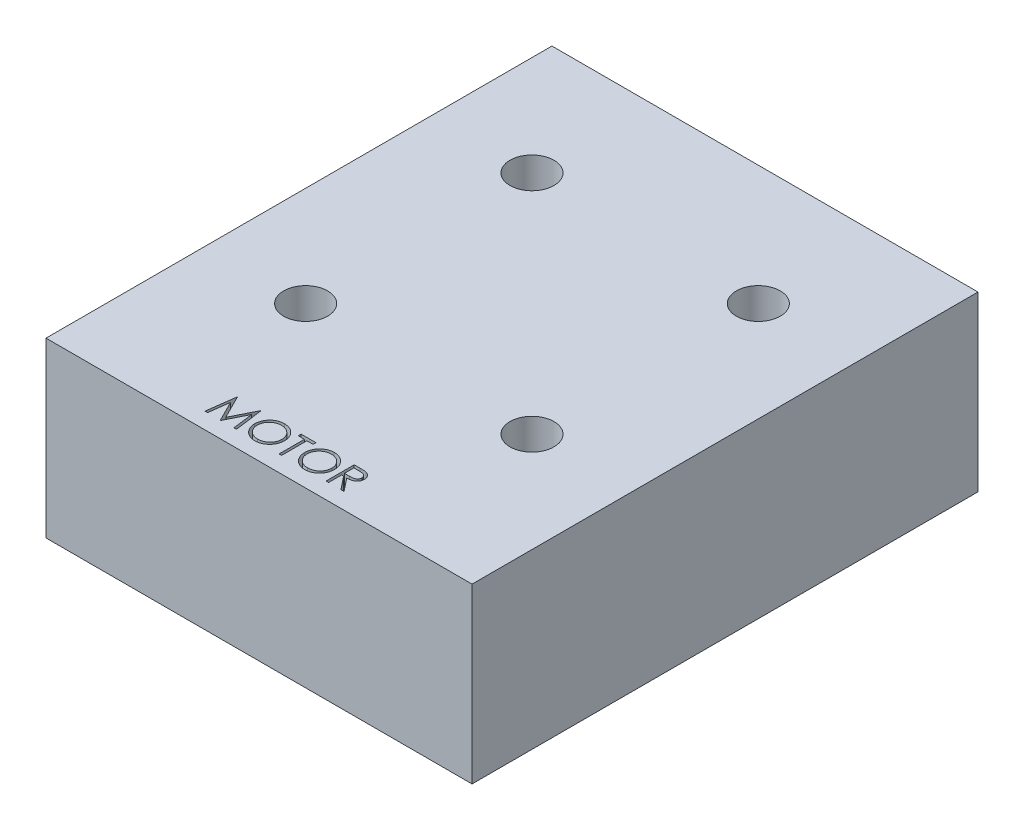
from build123d import *

# Parameters (mm, degrees)
SKETCH1_W                 = 16
SKETCH1_H                 = 13
BOSS_EXTRUDE1_DEPTH       = 19
M4X0_7_TAPPED_HOLE1_D     = 3.3
M4X0_7_TAPPED_HOLE1_DEPTH = 8
CUT_EXTRUDE1_DEPTH        = 1


with BuildPart() as part:
    # Sketch1 → Boss-Extrude1 (new, symmetric)
    with BuildSketch(Plane.XY):
        with Locations((-8, 6.5)):
            Rectangle(SKETCH1_W, SKETCH1_H)
    extrude(amount=BOSS_EXTRUDE1_DEPTH, both=True)

    # M4x0.7 Tapped Hole1
    with Locations(Plane(origin=(0, 13, 0), x_dir=(1, 0, 0), z_dir=(0, 1, 0))):
        with Locations((-8.5, 10), (-8.5, -7)):
            Hole(M4X0_7_TAPPED_HOLE1_D / 2, depth=M4X0_7_TAPPED_HOLE1_DEPTH)

    # Mirror1: part across plane


with BuildPart() as part_1:
    add(part.part)
    add(part.part.mirror(Plane(origin=(0, 0, 19), x_dir=(0, 0, 1), z_dir=(-1, 0, 0))))

    # Sketch9 → Cut-Extrude1 (cut)
    with BuildSketch(Plane(origin=(0, 13, 0), x_dir=(1, 0, 0), z_dir=(0, 1, 0))):
        Polygon((-5.278780125, -17.779725529), (-4.99935638, -15.663058862), (-4.972219628, -15.663058862), (-4.098331407, -17.399810999), (-3.226563244, -15.663058862), (-3.19900248, -15.663058862), (-2.917882689, -17.779725529), (-3.108687977, -17.779725529), (-3.311365595, -16.256675315), (-4.075434772, -17.779725529), (-4.118259959, -17.779725529), (-4.885297219, -16.253283221), (-5.087550825, -17.779725529), align=None)
        with BuildLine():
            add(Edge.make_bspline(
                [(-1.493203202, -15.608785358), (-1.454009728, -15.609778062), (-1.377030512, -15.611727815), (-1.263894741, -15.626652796), (-1.155887231, -15.652473342), (-1.052128147, -15.686861907), (-0.953858585, -15.73273575), (-0.860338874, -15.788183435), (-0.771791526, -15.853785865), (-0.689410024, -15.929035921), (-0.614022249, -16.010910676), (-0.547603737, -16.098285413), (-0.491940064, -16.190631831), (-0.44622866, -16.287672429), (-0.41036712, -16.389187743), (-0.385620841, -16.495718973), (-0.369813483, -16.606575876), (-0.367965466, -16.682187361), (-0.367027988, -16.720544172)],
                knots=[0, 0, 0, 0, 1.065120563, 2.091984664, 3.0946048, 4.079830382, 5.057816894, 6.036188127, 7.030412546, 8.04752943, 9.064399622, 10.05169764, 11.02544977, 11.989514704, 12.962713494, 13.945757189, 14.957906945, 16, 16, 16, 16], degree=3))
            add(Edge.make_bspline(
                [(-0.367027988, -16.720544172), (-0.367965328, -16.758618437), (-0.369812934, -16.833667225), (-0.385638814, -16.943820641), (-0.410458847, -17.049708824), (-0.445895637, -17.151155004), (-0.49138914, -17.248266198), (-0.547423458, -17.340786879), (-0.613427905, -17.428747381), (-0.688543476, -17.511184088), (-0.770428869, -17.586777796), (-0.858258601, -17.652647783), (-0.950057419, -17.709328563), (-1.047006623, -17.75455488), (-1.147820455, -17.790702661), (-1.253401193, -17.815348299), (-1.363254109, -17.831245701), (-1.438166573, -17.833071185), (-1.476242732, -17.833999033)],
                knots=[0, 0, 0, 0, 1.043624062, 2.057103931, 3.04512605, 4.022047818, 4.998200453, 5.980619268, 6.982898556, 8.009068085, 9.034988726, 10.034168286, 11.015286542, 11.987931943, 12.962482838, 13.94673481, 14.956375938, 16, 16, 16, 16], degree=3))
            add(Edge.make_bspline(
                [(-1.476242732, -17.833999033), (-1.514599344, -17.833062023), (-1.590210436, -17.831214926), (-1.701206643, -17.81538141), (-1.807812707, -17.790621669), (-1.909723767, -17.755237391), (-2.006996653, -17.709506971), (-2.099821608, -17.653745275), (-2.187826045, -17.587580004), (-2.270280339, -17.512488789), (-2.345723902, -17.430742184), (-2.411497429, -17.343151944), (-2.467271664, -17.251436501), (-2.512848537, -17.155341332), (-2.548931329, -17.055330983), (-2.573548052, -16.950738333), (-2.589475033, -16.842159679), (-2.591310392, -16.768231831), (-2.592241663, -16.730720454)],
                knots=[0, 0, 0, 0, 1.053102029, 2.075944431, 3.073151272, 4.055350789, 5.033113405, 6.020478099, 7.024410459, 8.052272461, 9.079885166, 10.07527673, 11.055994387, 12.023226415, 12.992069828, 13.970394897, 14.97016774, 16, 16, 16, 16], degree=3))
            add(Edge.make_bspline(
                [(-2.592241663, -16.730720454), (-2.591918336, -16.705542602), (-2.591275761, -16.655504527), (-2.583539832, -16.581199488), (-2.572314422, -16.508089423), (-2.556226599, -16.436382231), (-2.535185924, -16.366253445), (-2.510359222, -16.297219412), (-2.480036554, -16.229979732), (-2.445758257, -16.164215871), (-2.407499926, -16.100952994), (-2.365241734, -16.041154389), (-2.320467964, -15.984318263), (-2.271383435, -15.931917456), (-2.219605871, -15.882427578), (-2.164295328, -15.836609173), (-2.105789304, -15.794049083), (-2.043836055, -15.755694877), (-1.979962146, -15.721006258), (-1.914117618, -15.691238757), (-1.84719674, -15.665689949), (-1.778886071, -15.644982402), (-1.709367014, -15.628634456), (-1.63848784, -15.61750239), (-1.566305015, -15.609746731), (-1.517675313, -15.609107194), (-1.493203202, -15.608785358)],
                knots=[0, 0, 0, 0, 1.037015668, 2.060948919, 3.074880161, 4.083647147, 5.086022904, 6.090072063, 7.104153813, 8.122640571, 9.144368836, 10.147691507, 11.138137339, 12.123020368, 13.103399296, 14.087645067, 15.080126199, 16.082011238, 17.087798457, 18.072939717, 19.057185487, 20.037253025, 21.01195951, 21.997135196, 22.992090687, 24, 24, 24, 24], degree=3))
        make_face()
        with BuildLine():
            add(Edge.make_bspline(
                [(-1.483874943, -15.825879375), (-1.503961888, -15.826124237), (-1.543943746, -15.82661162), (-1.603382489, -15.833031601), (-1.662039516, -15.842181581), (-1.719926939, -15.855233263), (-1.776802553, -15.873015714), (-1.833196504, -15.893481406), (-1.888594541, -15.918410351), (-1.942813779, -15.946575749), (-1.995376706, -15.977750572), (-2.044974863, -16.012204927), (-2.091736653, -16.049130814), (-2.135547581, -16.088614411), (-2.176279004, -16.130856789), (-2.214732609, -16.175217548), (-2.24936707, -16.222964644), (-2.281108348, -16.272803319), (-2.309512708, -16.324668656), (-2.334770804, -16.37801462), (-2.355431895, -16.433276364), (-2.372281998, -16.489854355), (-2.386251884, -16.547658985), (-2.395101924, -16.60712876), (-2.401592446, -16.667964852), (-2.402051972, -16.709077688), (-2.402284398, -16.72987243)],
                knots=[0, 0, 0, 0, 1.008559885, 2.007477868, 2.99961109, 3.989939068, 4.984837346, 5.991145699, 7.001802488, 8.033829008, 9.059044045, 10.069351652, 11.065060232, 12.050310815, 13.029377138, 14.011219647, 14.996725999, 15.989392538, 16.977580475, 17.965360261, 18.951710183, 19.937753436, 20.929683414, 21.935841486, 22.955955122, 24, 24, 24, 24], degree=3))
            add(Edge.make_bspline(
                [(-2.402284398, -16.72987243), (-2.40151341, -16.760450535), (-2.399996638, -16.820607127), (-2.386717537, -16.908762148), (-2.366263295, -16.993482207), (-2.336111459, -17.074303742), (-2.298404182, -17.151921475), (-2.251821254, -17.225646853), (-2.196631235, -17.295499801), (-2.133939483, -17.360992654), (-2.065406227, -17.420770831), (-1.992633577, -17.473242035), (-1.916401157, -17.517637757), (-1.836510172, -17.553805587), (-1.753387137, -17.582465095), (-1.666496427, -17.602106934), (-1.576416864, -17.615033995), (-1.515014991, -17.616275423), (-1.483874943, -17.616905016)],
                knots=[0, 0, 0, 0, 1.032063989, 2.030389145, 3.003944642, 3.970395727, 4.937377036, 5.913328081, 6.909231446, 7.93887556, 8.970685674, 9.976071282, 10.964166581, 11.944589148, 12.933237628, 13.927779006, 14.949070134, 16, 16, 16, 16], degree=3))
            add(Edge.make_bspline(
                [(-1.483874943, -17.616905016), (-1.462944435, -17.616617449), (-1.421432951, -17.616047117), (-1.359689469, -17.610302679), (-1.299058331, -17.601091025), (-1.239624581, -17.5878282), (-1.181455671, -17.571229175), (-1.124308814, -17.551509263), (-1.068792705, -17.526906821), (-1.014206994, -17.499724012), (-0.961957838, -17.468735917), (-0.912079778, -17.435450941), (-0.865830019, -17.398579442), (-0.822051866, -17.359682479), (-0.781153216, -17.317975771), (-0.74341064, -17.273513541), (-0.708951226, -17.226015144), (-0.677222002, -17.176252065), (-0.648917172, -17.124244808), (-0.624255526, -17.070705431), (-0.603333113, -17.01576577), (-0.586443017, -16.959346581), (-0.573207524, -16.90155502), (-0.564087763, -16.842313706), (-0.557708469, -16.781741152), (-0.557227637, -16.740772248), (-0.556985253, -16.72012016)],
                knots=[0, 0, 0, 0, 1.047197238, 2.076906641, 3.100256066, 4.114471768, 5.12198147, 6.126382909, 7.136867548, 8.15857795, 9.17633901, 10.174870724, 11.156907918, 12.133735059, 13.104061851, 14.077631395, 15.04955518, 16.038496417, 17.029181396, 18.010275684, 18.986308667, 19.968651475, 20.955262928, 21.950658345, 22.966943676, 24, 24, 24, 24], degree=3))
            add(Edge.make_bspline(
                [(-0.556985253, -16.72012016), (-0.557227831, -16.699609355), (-0.557709029, -16.658922395), (-0.564084716, -16.598772281), (-0.573217159, -16.539957244), (-0.586378416, -16.482708182), (-0.60334208, -16.427010503), (-0.62425918, -16.372916517), (-0.648924575, -16.320224704), (-0.677232406, -16.269065296), (-0.709052452, -16.219973906), (-0.74382278, -16.173042924), (-0.782143729, -16.129153694), (-0.82292042, -16.087222713), (-0.867171384, -16.048144275), (-0.914696171, -16.011905417), (-0.964917824, -15.97763158), (-1.018092866, -15.946712788), (-1.072971353, -15.918159418), (-1.129283127, -15.893696193), (-1.186390249, -15.872909244), (-1.244147498, -15.855179461), (-1.303041014, -15.842232699), (-1.362672853, -15.833023355), (-1.422960514, -15.826613855), (-1.463505699, -15.826124978), (-1.483874943, -15.825879375)],
                knots=[0, 0, 0, 0, 1.02996197, 2.043119294, 3.035359645, 4.018872909, 4.991431989, 5.957985074, 6.929999688, 7.912076566, 8.892894881, 9.867085534, 10.843653904, 11.817741046, 12.803660682, 13.806313499, 14.818574707, 15.856120519, 16.894564902, 17.924820532, 18.937903209, 19.946497019, 20.957711757, 21.963978472, 22.977135795, 24, 24, 24, 24], degree=3))
        make_face(mode=Mode.SUBTRACT)
        Polygon((-0.177070723, -15.880152879), (-0.177070723, -15.663058862), (0.935536115, -15.663058862), (0.935536115, -15.880152879), (0.474211328, -15.880152879), (0.474211328, -17.779725529), (0.284254063, -17.779725529), (0.284254063, -15.880152879), align=None)
        with BuildLine():
            add(Edge.make_bspline(
                [(2.251668593, -15.608785358), (2.290862067, -15.609778062), (2.367841283, -15.611727815), (2.480977054, -15.626652796), (2.588984564, -15.652473342), (2.692743648, -15.686861907), (2.79101321, -15.73273575), (2.884532921, -15.788183435), (2.973080269, -15.853785865), (3.055461771, -15.929035921), (3.130849546, -16.010910676), (3.197268058, -16.098285413), (3.252931731, -16.190631831), (3.298643135, -16.287672429), (3.334504675, -16.389187743), (3.359250954, -16.495718973), (3.375058312, -16.606575876), (3.376906329, -16.682187361), (3.377843807, -16.720544172)],
                knots=[0, 0, 0, 0, 1.065120563, 2.091984664, 3.0946048, 4.079830382, 5.057816894, 6.036188127, 7.030412546, 8.04752943, 9.064399622, 10.05169764, 11.02544977, 11.989514704, 12.962713494, 13.945757189, 14.957906945, 16, 16, 16, 16], degree=3))
            add(Edge.make_bspline(
                [(3.377843807, -16.720544172), (3.376906467, -16.758618437), (3.375058861, -16.833667225), (3.359232981, -16.943820641), (3.334412948, -17.049708824), (3.298976158, -17.151155004), (3.253482654, -17.248266198), (3.197448337, -17.340786879), (3.13144389, -17.428747381), (3.056328318, -17.511184088), (2.974442926, -17.586777796), (2.886613194, -17.652647783), (2.794814376, -17.709328563), (2.697865172, -17.75455488), (2.59705134, -17.790702661), (2.491470602, -17.815348299), (2.381617686, -17.831245701), (2.306705222, -17.833071185), (2.268629063, -17.833999033)],
                knots=[0, 0, 0, 0, 1.043624062, 2.057103931, 3.04512605, 4.022047818, 4.998200453, 5.980619268, 6.982898556, 8.009068085, 9.034988726, 10.034168286, 11.015286542, 11.987931943, 12.962482838, 13.94673481, 14.956375938, 16, 16, 16, 16], degree=3))
            add(Edge.make_bspline(
                [(2.268629063, -17.833999033), (2.230272451, -17.833062023), (2.154661359, -17.831214926), (2.043665152, -17.81538141), (1.937059088, -17.790621669), (1.835148028, -17.755237391), (1.737875142, -17.709506971), (1.645050187, -17.653745275), (1.55704575, -17.587580004), (1.474591456, -17.512488789), (1.399147893, -17.430742184), (1.333374366, -17.343151944), (1.277600131, -17.251436501), (1.232023258, -17.155341332), (1.195940466, -17.055330983), (1.171323743, -16.950738333), (1.155396762, -16.842159679), (1.153561403, -16.768231831), (1.152630132, -16.730720454)],
                knots=[0, 0, 0, 0, 1.053102029, 2.075944431, 3.073151272, 4.055350789, 5.033113405, 6.020478099, 7.024410459, 8.052272461, 9.079885166, 10.07527673, 11.055994387, 12.023226415, 12.992069828, 13.970394897, 14.97016774, 16, 16, 16, 16], degree=3))
            add(Edge.make_bspline(
                [(1.152630132, -16.730720454), (1.152953459, -16.705542602), (1.153596034, -16.655504527), (1.161331963, -16.581199488), (1.172557372, -16.508089423), (1.188645196, -16.436382231), (1.209685871, -16.366253445), (1.234512573, -16.297219412), (1.264835241, -16.229979732), (1.299113538, -16.164215871), (1.337371869, -16.100952994), (1.379630061, -16.041154389), (1.424403831, -15.984318263), (1.47348836, -15.931917456), (1.525265924, -15.882427578), (1.580576467, -15.836609173), (1.639082491, -15.794049083), (1.70103574, -15.755694877), (1.764909649, -15.721006258), (1.830754176, -15.691238757), (1.897675055, -15.665689949), (1.965985723, -15.644982402), (2.035504781, -15.628634456), (2.106383955, -15.61750239), (2.17856678, -15.609746731), (2.227196482, -15.609107194), (2.251668593, -15.608785358)],
                knots=[0, 0, 0, 0, 1.037015668, 2.060948919, 3.074880161, 4.083647147, 5.086022904, 6.090072063, 7.104153813, 8.122640571, 9.144368836, 10.147691507, 11.138137339, 12.123020368, 13.103399296, 14.087645067, 15.080126199, 16.082011238, 17.087798457, 18.072939717, 19.057185487, 20.037253025, 21.01195951, 21.997135196, 22.992090687, 24, 24, 24, 24], degree=3))
        make_face()
        with BuildLine():
            add(Edge.make_bspline(
                [(2.260996852, -15.825879375), (2.240909907, -15.826124237), (2.200928049, -15.82661162), (2.141489306, -15.833031601), (2.082832279, -15.842181581), (2.024944855, -15.855233263), (1.968069242, -15.873015714), (1.911675291, -15.893481406), (1.856277253, -15.918410351), (1.802058016, -15.946575749), (1.749495089, -15.977750572), (1.699896932, -16.012204927), (1.653135142, -16.049130814), (1.609324214, -16.088614411), (1.568592791, -16.130856789), (1.530139186, -16.175217548), (1.495504725, -16.222964644), (1.463763447, -16.272803319), (1.435359087, -16.324668656), (1.410100991, -16.37801462), (1.3894399, -16.433276364), (1.372589796, -16.489854355), (1.358619911, -16.547658985), (1.349769871, -16.60712876), (1.343279349, -16.667964852), (1.342819823, -16.709077688), (1.342587397, -16.72987243)],
                knots=[0, 0, 0, 0, 1.008559885, 2.007477868, 2.99961109, 3.989939068, 4.984837346, 5.991145699, 7.001802488, 8.033829008, 9.059044045, 10.069351652, 11.065060232, 12.050310815, 13.029377138, 14.011219647, 14.996725999, 15.989392538, 16.977580475, 17.965360261, 18.951710183, 19.937753436, 20.929683414, 21.935841486, 22.955955122, 24, 24, 24, 24], degree=3))
            add(Edge.make_bspline(
                [(1.342587397, -16.72987243), (1.343358385, -16.760450535), (1.344875156, -16.820607127), (1.358154258, -16.908762148), (1.3786085, -16.993482207), (1.408760336, -17.074303742), (1.446467612, -17.151921475), (1.493050541, -17.225646853), (1.54824056, -17.295499801), (1.610932311, -17.360992654), (1.679465567, -17.420770831), (1.752238218, -17.473242035), (1.828470638, -17.517637757), (1.908361623, -17.553805587), (1.991484658, -17.582465095), (2.078375368, -17.602106934), (2.168454931, -17.615033995), (2.229856804, -17.616275423), (2.260996852, -17.616905016)],
                knots=[0, 0, 0, 0, 1.032063989, 2.030389145, 3.003944642, 3.970395727, 4.937377036, 5.913328081, 6.909231446, 7.93887556, 8.970685674, 9.976071282, 10.964166581, 11.944589148, 12.933237628, 13.927779006, 14.949070134, 16, 16, 16, 16], degree=3))
            add(Edge.make_bspline(
                [(2.260996852, -17.616905016), (2.28192736, -17.616617449), (2.323438844, -17.616047117), (2.385182326, -17.610302679), (2.445813464, -17.601091025), (2.505247214, -17.5878282), (2.563416124, -17.571229175), (2.620562981, -17.551509263), (2.67607909, -17.526906821), (2.730664801, -17.499724012), (2.782913957, -17.468735917), (2.832792017, -17.435450941), (2.879041776, -17.398579442), (2.922819929, -17.359682479), (2.963718579, -17.317975771), (3.001461155, -17.273513541), (3.035920568, -17.226015144), (3.067649793, -17.176252065), (3.095954623, -17.124244808), (3.120616269, -17.070705431), (3.141538682, -17.01576577), (3.158428777, -16.959346581), (3.171664271, -16.90155502), (3.180784032, -16.842313706), (3.187163326, -16.781741152), (3.187644158, -16.740772248), (3.187886542, -16.72012016)],
                knots=[0, 0, 0, 0, 1.047197238, 2.076906641, 3.100256066, 4.114471768, 5.12198147, 6.126382909, 7.136867548, 8.15857795, 9.17633901, 10.174870724, 11.156907918, 12.133735059, 13.104061851, 14.077631395, 15.04955518, 16.038496417, 17.029181396, 18.010275684, 18.986308667, 19.968651475, 20.955262928, 21.950658345, 22.966943676, 24, 24, 24, 24], degree=3))
            add(Edge.make_bspline(
                [(3.187886542, -16.72012016), (3.187643964, -16.699609355), (3.187162766, -16.658922395), (3.180787079, -16.598772281), (3.171654636, -16.539957244), (3.158493379, -16.482708182), (3.141529715, -16.427010503), (3.120612615, -16.372916517), (3.09594722, -16.320224704), (3.067639389, -16.269065296), (3.035819343, -16.219973906), (3.001049015, -16.173042924), (2.962728066, -16.129153694), (2.921951375, -16.087222713), (2.877700411, -16.048144275), (2.830175624, -16.011905417), (2.779953971, -15.97763158), (2.726778929, -15.946712788), (2.671900442, -15.918159418), (2.615588668, -15.893696193), (2.558481546, -15.872909244), (2.500724297, -15.855179461), (2.441830781, -15.842232699), (2.382198942, -15.833023355), (2.321911281, -15.826613855), (2.281366095, -15.826124978), (2.260996852, -15.825879375)],
                knots=[0, 0, 0, 0, 1.02996197, 2.043119294, 3.035359645, 4.018872909, 4.991431989, 5.957985074, 6.929999688, 7.912076566, 8.892894881, 9.867085534, 10.843653904, 11.817741046, 12.803660682, 13.806313499, 14.818574707, 15.856120519, 16.894564902, 17.924820532, 18.937903209, 19.946497019, 20.957711757, 21.963978472, 22.977135795, 24, 24, 24, 24], degree=3))
        make_face(mode=Mode.SUBTRACT)
        with BuildLine():
            Line((3.812031841, -15.663058862), (4.235619581, -15.663058862))
            add(Edge.make_bspline(
                [(4.235619581, -15.663058862), (4.263886835, -15.663152954), (4.318163094, -15.663333622), (4.39591931, -15.664341012), (4.466571888, -15.667228361), (4.530083886, -15.669713076), (4.586454139, -15.674243916), (4.635855501, -15.678574403), (4.678060441, -15.684243236), (4.703609123, -15.689507944), (4.715176873, -15.691891661)],
                knots=[0, 0, 0, 0, 1.410062039, 2.707475311, 3.878576406, 4.937260626, 5.877586885, 6.699081471, 7.410979367, 8, 8, 8, 8], degree=3))
            add(Edge.make_bspline(
                [(4.715176873, -15.691891661), (4.730662784, -15.695717848), (4.761304249, -15.703288598), (4.80542167, -15.719290357), (4.847461285, -15.737807939), (4.887248464, -15.759557427), (4.924583919, -15.78470027), (4.959852612, -15.81280242), (4.993214582, -15.843710112), (5.023320616, -15.878202611), (5.051707566, -15.914389452), (5.075649259, -15.95351982), (5.096287654, -15.994438934), (5.112719348, -16.037562944), (5.125950313, -16.082473634), (5.135279515, -16.129577811), (5.140874281, -16.178660877), (5.141443879, -16.212139232), (5.141732696, -16.229114551)],
                knots=[0, 0, 0, 0, 1.027469482, 2.033020251, 3.019912614, 3.986113645, 4.951240523, 5.91722682, 6.890402269, 7.87763091, 8.8651537, 9.85103654, 10.82876324, 11.815024772, 12.821070561, 13.842952187, 14.906261191, 16, 16, 16, 16], degree=3))
            add(Edge.make_bspline(
                [(5.141732696, -16.229114551), (5.140844302, -16.257317686), (5.139110815, -16.312349306), (5.12294849, -16.392214696), (5.096474119, -16.466714901), (5.059992891, -16.535756115), (5.013535399, -16.597992553), (4.957700883, -16.652657257), (4.892458194, -16.698401395), (4.831722369, -16.730122853), (4.778071401, -16.750438564), (4.733903636, -16.764732934), (4.685724082, -16.775777075), (4.633994361, -16.785671059), (4.578499198, -16.793140893), (4.519371603, -16.798611929), (4.456569406, -16.802031282), (4.413426255, -16.802540495), (4.391231895, -16.802802452)],
                knots=[0, 0, 0, 0, 1.260483769, 2.459530307, 3.627416485, 4.787058657, 5.939039949, 7.08810263, 8.267026773, 9.491475466, 10.141966685, 10.831826277, 11.566392101, 12.351337768, 13.187381173, 14.07005841, 15.007169909, 16, 16, 16, 16], degree=3))
            Line((4.391231895, -16.802802452), (5.168869448, -17.779725529))
            Line((5.168869448, -17.779725529), (4.933966937, -17.779725529))
            Line((4.933966937, -17.779725529), (4.156329384, -16.802802452))
            Line((4.156329384, -16.802802452), (4.001989106, -16.802802452))
            Line((4.001989106, -16.802802452), (4.001989106, -17.779725529))
            Line((4.001989106, -17.779725529), (3.812031841, -17.779725529))
            Line((3.812031841, -17.779725529), (3.812031841, -15.663058862))
        make_face()
        with BuildLine():
            Line((4.001989106, -15.880152879), (4.001989106, -16.585708435))
            Line((4.001989106, -16.585708435), (4.389535847, -16.588676517))
            add(Edge.make_bspline(
                [(4.389535847, -16.588676517), (4.407630347, -16.588684522), (4.442702641, -16.588700038), (4.493442567, -16.586284754), (4.540686635, -16.583537128), (4.584254137, -16.579334429), (4.624164538, -16.573918138), (4.660397887, -16.567143), (4.693013333, -16.55924961), (4.731051973, -16.547032436), (4.773528351, -16.527676415), (4.819690711, -16.499515376), (4.859001648, -16.464095004), (4.892213879, -16.423592009), (4.918901678, -16.379059611), (4.937717063, -16.331031616), (4.94965654, -16.280720507), (4.951064756, -16.246141365), (4.951775431, -16.228690539)],
                knots=[0, 0, 0, 0, 1.146690395, 2.22261258, 3.21895312, 4.145990853, 4.996080663, 5.770904154, 6.481378293, 7.121626537, 8.300444488, 9.431385265, 10.535395872, 11.636531494, 12.74115979, 13.810798291, 14.895190096, 16, 16, 16, 16], degree=3))
            add(Edge.make_bspline(
                [(4.951775431, -16.228690539), (4.951048434, -16.211668564), (4.949607791, -16.177937219), (4.937845917, -16.128554836), (4.917955672, -16.08194768), (4.891151271, -16.038305349), (4.858494639, -15.998689975), (4.820202438, -15.964794792), (4.777321677, -15.936824878), (4.737243381, -15.918951514), (4.701420786, -15.907993317), (4.670318086, -15.900281899), (4.635174479, -15.894086435), (4.59581932, -15.889122512), (4.55242062, -15.88485595), (4.50475894, -15.881982256), (4.453150506, -15.880280538), (4.417380696, -15.880196422), (4.398864106, -15.880152879)],
                knots=[0, 0, 0, 0, 1.101028733, 2.181837193, 3.264309656, 4.369019818, 5.486613113, 6.575447106, 7.666700264, 8.788928104, 9.402425223, 10.0903467, 10.862060571, 11.710948788, 12.657782767, 13.684531032, 14.801375019, 16, 16, 16, 16], degree=3))
            Line((4.398864106, -15.880152879), (4.001989106, -15.880152879))
        make_face(mode=Mode.SUBTRACT)
    extrude(amount=-CUT_EXTRUDE1_DEPTH, mode=Mode.SUBTRACT)


solid = part_1.part
